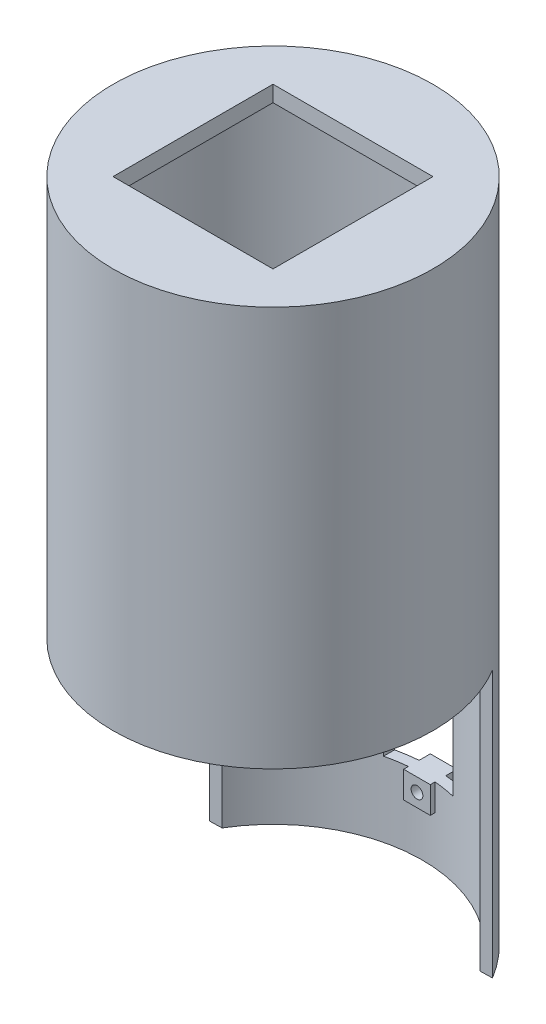
from build123d import *

# Parameters (mm, degrees)
EXTRUDE_1_DEPTH           = 75
EXTRUDE_1_DEPTH_BACK      = 50
SKETCH_1_R                = 30
SKETCH_10_W               = 30
SKETCH_10_H               = 30
CUT_EXTRUDE_8_DEPTH       = 45.1
CUT_EXTRUDE_9_DEPTH       = 10
CUT_EXTRUDE_9_DEPTH_BACK  = 113
SKETCH_10_2_W             = 30
SKETCH_10_2_H             = 30
CUT_EXTRUDE_10_DEPTH      = 54
CUT_EXTRUDE_11_DEPTH      = 72
CUT_EXTRUDE_11_DEPTH_BACK = 55
SKETCH_12_R               = 28
SKETCH_13_W               = 13
SKETCH_13_H               = 23.5
CUT_EXTRUDE_12_DEPTH      = 54
EXTRUDE_2_DEPTH           = 1
EXTRUDE_2_DEPTH_BACK      = 4
SKETCH_14_W               = 5
SKETCH_14_H               = 5
CUT_EXTRUDE_13_DEPTH      = 4
CUT_EXTRUDE_13_DEPTH_BACK = 5
SKETCH_15_R               = 1.1


with BuildPart() as part:
    # 草圖1 → 填料-伸長1 (new, two sides: drawn at the far end of the back side and taken through both)
    with BuildSketch(Plane(origin=(0, 0, 0), x_dir=(1, 0, 0), z_dir=(0, 1, 0)).offset(-EXTRUDE_1_DEPTH_BACK)):
        Circle(SKETCH_1_R)
    extrude(amount=EXTRUDE_1_DEPTH + EXTRUDE_1_DEPTH_BACK)

    # 草圖10 → 除料-伸長8 (cut)
    with BuildSketch(Plane(origin=(0, 75, 0), x_dir=(1, 0, 0), z_dir=(0, 1, 0))):
        Rectangle(SKETCH_10_W, SKETCH_10_H)
    extrude(amount=-CUT_EXTRUDE_8_DEPTH, mode=Mode.SUBTRACT)

    # 草圖10<2> → 除料-伸長9 (cut, two sides: drawn at the far end of the back side and taken through both)
    with BuildSketch(Plane(origin=(0, 75, 0), x_dir=(1, 0, 0), z_dir=(0, 1, 0)).offset(-CUT_EXTRUDE_9_DEPTH_BACK)):
        Rectangle(SKETCH_10_2_W, SKETCH_10_2_H)
    extrude(amount=CUT_EXTRUDE_9_DEPTH + CUT_EXTRUDE_9_DEPTH_BACK, mode=Mode.SUBTRACT)

    # 草圖11 → 除料-伸長10 (cut)
    with BuildSketch(Plane(origin=(0, 0, 0), x_dir=(1, 0, 0), z_dir=(0, 1, 0))):
        with BuildLine():
            Line((25.732316415, 15.422317981), (-26.32585788, 14.385729278))
            ThreePointArc((-26.32585788, 14.385729278), (0.597245261, -29.994054379), (25.732316415, 15.422317981))
        make_face()
    extrude(amount=-CUT_EXTRUDE_10_DEPTH, mode=Mode.SUBTRACT)

    # 草圖12 → 除料-伸長11 (cut, two sides: drawn at the far end of the back side and taken through both)
    with BuildSketch(Plane(origin=(0, 0, 0), x_dir=(1, 0, 0), z_dir=(0, 1, 0)).offset(-CUT_EXTRUDE_11_DEPTH_BACK)):
        Circle(SKETCH_12_R)
    extrude(amount=CUT_EXTRUDE_11_DEPTH + CUT_EXTRUDE_11_DEPTH_BACK, mode=Mode.SUBTRACT)

    # 草圖13 → 除料-伸長12 (cut)
    with BuildSketch(Plane.XY):
        with Locations((0, -24.25)):
            Rectangle(SKETCH_13_W, SKETCH_13_H)
    extrude(amount=-CUT_EXTRUDE_12_DEPTH, mode=Mode.SUBTRACT)

    # 草圖14 → 填料-伸長2 (add, two sides: drawn at the far end of the back side and taken through both)
    with BuildSketch(Plane.XY.offset(-28).offset(-EXTRUDE_2_DEPTH_BACK)):
        with Locations((0, -38.5)):
            Rectangle(SKETCH_14_W, SKETCH_14_H)
        with Locations((0, -10)):
            Rectangle(SKETCH_14_W, SKETCH_14_H)
    extrude(amount=EXTRUDE_2_DEPTH + EXTRUDE_2_DEPTH_BACK)

    # 草圖15 → 除料-伸長13 (cut, two sides: drawn at the far end of the back side and taken through both)
    with BuildSketch(Plane.XY.offset(-28).offset(-CUT_EXTRUDE_13_DEPTH_BACK)):
        with Locations((0, -10)):
            Circle(SKETCH_15_R)
        with Locations((0, -38.5)):
            Circle(SKETCH_15_R)
    extrude(amount=CUT_EXTRUDE_13_DEPTH + CUT_EXTRUDE_13_DEPTH_BACK, mode=Mode.SUBTRACT)


solid = part.part
